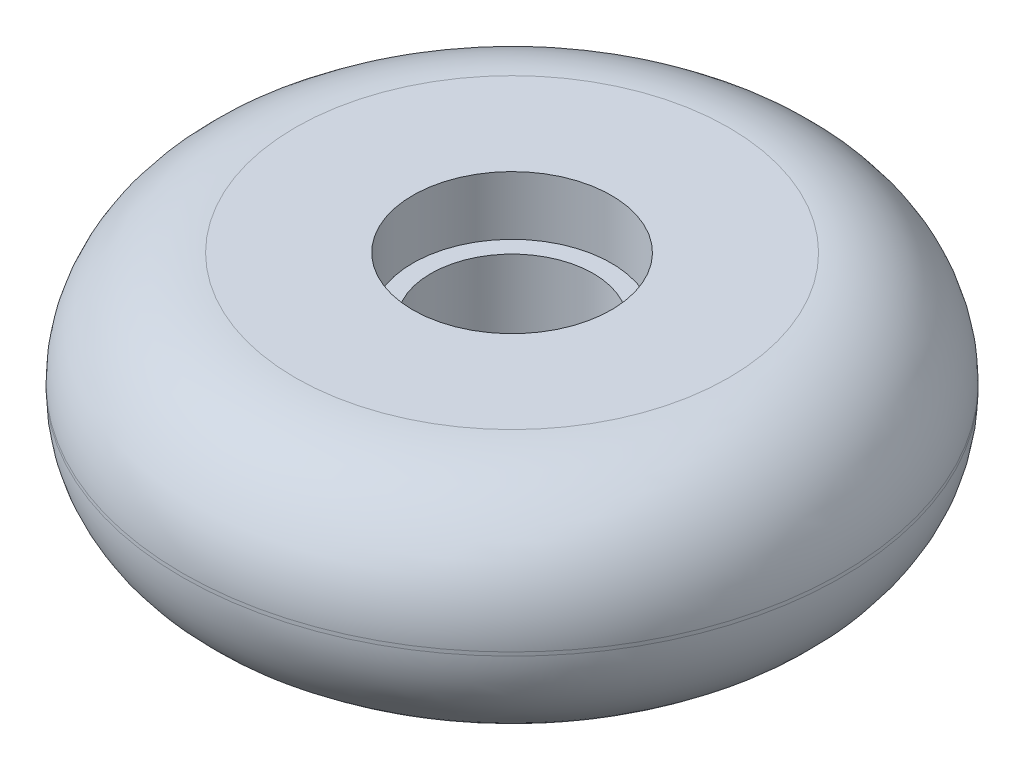
from build123d import *

# Parameters (mm, degrees)
SKETCH1_R           = 36.5125
BOSS_EXTRUDE1_DEPTH = 25.4
FILLET1_R           = 12.5
SKETCH2_R           = 11
CUT_EXTRUDE1_DEPTH  = 6.5
SKETCH3_R           = 11
CUT_EXTRUDE2_DEPTH  = 6.5
SKETCH4_R           = 9
CUT_EXTRUDE3_DEPTH  = 19.9


with BuildPart() as part:
    # Sketch1 → Boss-Extrude1 (new body)
    with BuildSketch(Plane(origin=(0, 0, 0), x_dir=(1, 0, 0), z_dir=(0, 1, 0))):
        Circle(SKETCH1_R)
    extrude(amount=BOSS_EXTRUDE1_DEPTH)

    # Fillet1
    fillet1_edges = [part.edges().sort_by_distance(p)[0] for p in [
        (-36.5125, 0, 0),
        (-36.5125, 25.4, 0),
    ]]
    fillet(fillet1_edges, radius=FILLET1_R)

    # Sketch2 → Cut-Extrude1 (cut)
    with BuildSketch(Plane(origin=(0, 25.4, 0), x_dir=(1, 0, 0), z_dir=(0, 1, 0))):
        Circle(SKETCH2_R)
    extrude(amount=-CUT_EXTRUDE1_DEPTH, mode=Mode.SUBTRACT)

    # Sketch3 → Cut-Extrude2 (cut)
    with BuildSketch(Plane.XZ):
        Circle(SKETCH3_R)
    extrude(amount=-CUT_EXTRUDE2_DEPTH, mode=Mode.SUBTRACT)

    # Sketch4 → Cut-Extrude3 (cut, through all)
    with BuildSketch(Plane.XZ.offset(-6.5)):
        Circle(SKETCH4_R)
    extrude(amount=-CUT_EXTRUDE3_DEPTH, mode=Mode.SUBTRACT)


solid = part.part
